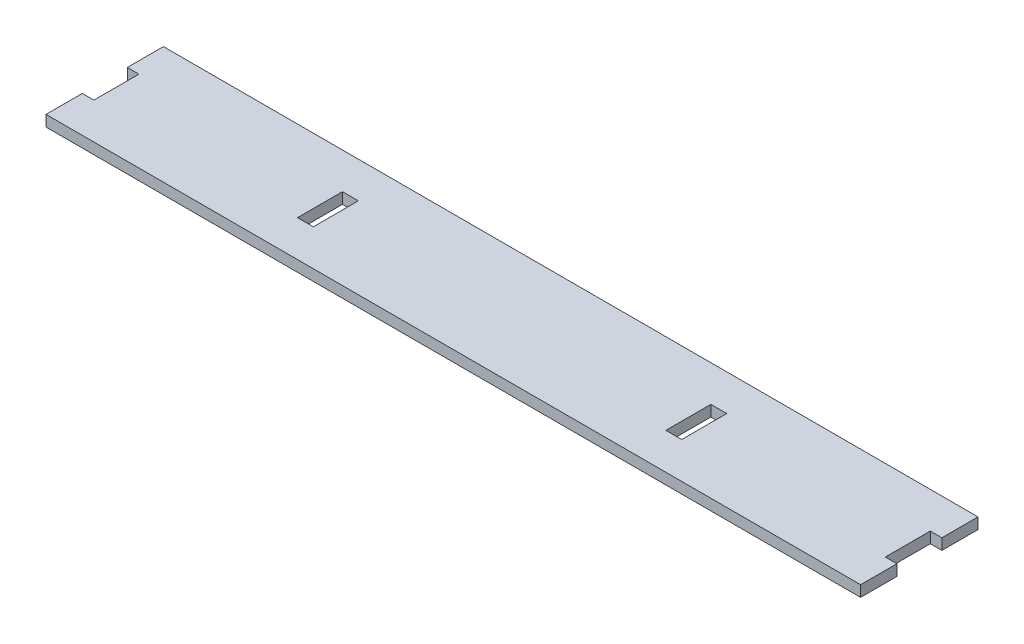
from build123d import *

# Parameters (mm, degrees)
SKETCH1_W           = 355.6
SKETCH1_H           = 50.8
BOSS_EXTRUDE1_DEPTH = 4.7625
SKETCH2_W           = 6.858
SKETCH2_H           = 19.471321321
SKETCH2_W_2         = 6.35
SKETCH2_H_2         = 18.963321321
CUT_EXTRUDE1_DEPTH  = 180.668253752
SKETCH3_W           = 1.5875
SKETCH3_H           = 15.707678679
SKETCH3_H_2         = 15.621
CUT_EXTRUDE2_DEPTH  = 180.668253752
SKETCH4_W           = 0.3175
SKETCH4_H           = 19.471321321
BOSS_EXTRUDE2_DEPTH = 4.7625
SKETCH5_W           = 0.3175
SKETCH5_H           = 19.471321321
CUT_EXTRUDE4_DEPTH  = 179.097407512


with BuildPart() as part:
    # Sketch1 → Boss-Extrude1 (new body)
    with BuildSketch(Plane(origin=(0, 0, 0), x_dir=(1, 0, 0), z_dir=(0, 1, 0))):
        Rectangle(SKETCH1_W, SKETCH1_H)
    extrude(amount=BOSS_EXTRUDE1_DEPTH)

    # Sketch2 → Cut-Extrude1 (cut, through all)
    with BuildSketch(Plane(origin=(0, 0, 0), x_dir=(-1, 0, 0), z_dir=(0, -1, 0))):
        with Locations((174.625, 0.043339339)):
            Rectangle(SKETCH2_W, SKETCH2_H)
        with Locations((174.625, 0.04333934)):
            Rectangle(SKETCH2_W_2, SKETCH2_H_2, mode=Mode.SUBTRACT)
        with Locations((79.375, 0.043339339)):
            Rectangle(SKETCH2_W, SKETCH2_H)
        with Locations((79.375, 0.04333934)):
            Rectangle(SKETCH2_W_2, SKETCH2_H_2, mode=Mode.SUBTRACT)
        with Locations((-79.375, 0.043339339)):
            Rectangle(SKETCH2_W, SKETCH2_H)
        with Locations((-79.375, 0.04333934)):
            Rectangle(SKETCH2_W_2, SKETCH2_H_2, mode=Mode.SUBTRACT)
        with Locations((-174.625, 0.043339339)):
            Rectangle(SKETCH2_W, SKETCH2_H)
        with Locations((-174.625, 0.04333934)):
            Rectangle(SKETCH2_W_2, SKETCH2_H_2, mode=Mode.SUBTRACT)
    extrude(amount=-CUT_EXTRUDE1_DEPTH, mode=Mode.SUBTRACT)


with BuildPart() as body_2:
    # of the pieces the cut leaves, the one that is kept (cut_extrude1_keep)
    add(part.part.solids().sort_by_distance((-177.8, 0, -25.4))[0])

    # Sketch3 → Cut-Extrude2 (cut, through all)
    with BuildSketch(Plane(origin=(0, 4.7625, 0), x_dir=(1, 0, 0), z_dir=(0, 1, 0))):
        with Locations((-177.00625, -17.546160661)):
            Rectangle(SKETCH3_W, SKETCH3_H)
        with Locations((-177.00625, 17.5895)):
            Rectangle(SKETCH3_W, SKETCH3_H_2)
        with Locations((177.00625, -17.546160661)):
            Rectangle(SKETCH3_W, SKETCH3_H)
        with Locations((177.00625, 17.5895)):
            Rectangle(SKETCH3_W, SKETCH3_H_2)
    extrude(amount=-CUT_EXTRUDE2_DEPTH, mode=Mode.SUBTRACT)

    # Sketch4 → Boss-Extrude2 (add)
    with BuildSketch(Plane(origin=(0, 4.7625, 0), x_dir=(1, 0, 0), z_dir=(0, 1, 0))):
        with Locations((-76.10475, 0.043339339)):
            Rectangle(SKETCH4_W, SKETCH4_H)
        with Locations((76.10475, 0.043339339)):
            Rectangle(SKETCH4_W, SKETCH4_H)
    extrude(amount=-BOSS_EXTRUDE2_DEPTH)

    # Sketch5 → Cut-Extrude4 (cut, through all)
    with BuildSketch(Plane(origin=(0, 4.7625, 0), x_dir=(1, 0, 0), z_dir=(0, 1, 0))):
        with Locations((-82.96275, 0.043339339)):
            Rectangle(SKETCH5_W, SKETCH5_H)
        with Locations((82.96275, 0.043339339)):
            Rectangle(SKETCH5_W, SKETCH5_H)
    extrude(amount=-CUT_EXTRUDE4_DEPTH, mode=Mode.SUBTRACT)


solid = body_2.part
